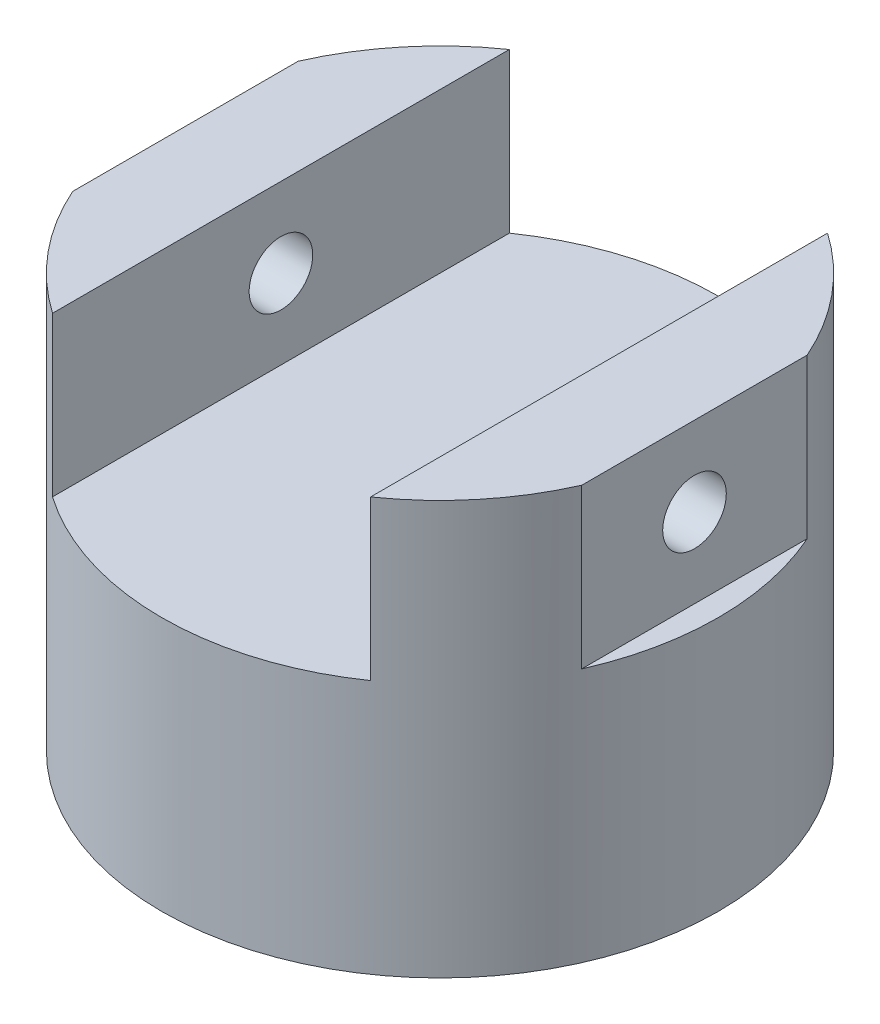
from build123d import *

# Parameters (mm, degrees)
ESBO_O1_W                  = 175
ESBO_O1_H                  = 260
ESBO_O2_W                  = 200
ESBO_O2_H                  = 100
ESBO_O2_W_2                = 15
CORTE_EXTRUS_O1_DEPTH      = 176
CORTE_EXTRUS_O1_DEPTH_BACK = 176
ESBO_O3_R                  = 20
CORTE_EXTRUS_O2_DEPTH      = 16
CORTE_EXTRUS_O2_DEPTH_BACK = 336


with BuildPart() as part:
    # Esboço1 → Revolução1 (revolve)
    with BuildSketch(Plane.XY):
        with Locations((87.5, 130)):
            Rectangle(ESBO_O1_W, ESBO_O1_H)
    revolve(axis=Axis((0, 0, 0), (0, 1, 0)))

    # Esboço2 → Corte-extrusão1 (cut, two sides)
    with BuildSketch(Plane.XY) as corte_extrus_o1_sk:
        with Locations((0, 210)):
            Rectangle(ESBO_O2_W, ESBO_O2_H)
        with Locations((167.5, 210)):
            Rectangle(ESBO_O2_W_2, ESBO_O2_H)
        with Locations((-167.5, 210)):
            Rectangle(ESBO_O2_W_2, ESBO_O2_H)
    extrude(amount=CORTE_EXTRUS_O1_DEPTH, mode=Mode.SUBTRACT)
    extrude(corte_extrus_o1_sk.sketch, amount=-CORTE_EXTRUS_O1_DEPTH_BACK, mode=Mode.SUBTRACT)

    # Esboço3 → Corte-extrusão2 (cut, two sides)
    with BuildSketch(Plane(origin=(160, 0, 0), x_dir=(0, 0, -1), z_dir=(1, 0, 0))) as corte_extrus_o2_sk:
        with Locations((0, 210)):
            Circle(ESBO_O3_R)
    extrude(amount=CORTE_EXTRUS_O2_DEPTH, mode=Mode.SUBTRACT)
    extrude(corte_extrus_o2_sk.sketch, amount=-CORTE_EXTRUS_O2_DEPTH_BACK, mode=Mode.SUBTRACT)


solid = part.part
